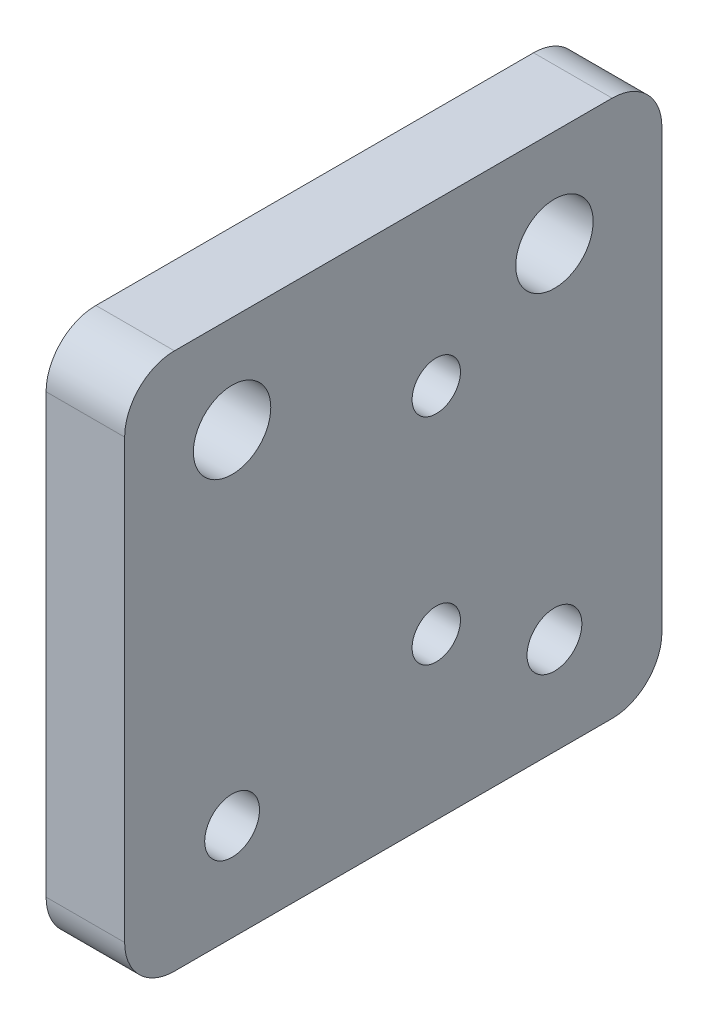
from build123d import *

# Parameters (mm, degrees)
SKETCH2_W            = 50
SKETCH2_H            = 50
BOSS_EXTRUDE1_DEPTH  = 7.31
SKETCH6_R            = 3.6
SKETCH6_R_2          = 2.55
CUT_EXTRUDE2_DEPTH   = 8.31
SKETCH7_R            = 5.05
SKETCH7_R_2          = 6
CUT_EXTRUDE3_DEPTH   = 2
M4_CLEARANCE_HOLE1_D = 4.5
FILLET1_R            = 4.635


with BuildPart() as part:
    # Sketch2 → Boss-Extrude1 (new body)
    with BuildSketch(Plane(origin=(0, 0, 0), x_dir=(0, 0, -1), z_dir=(1, 0, 0))):
        Rectangle(SKETCH2_W, SKETCH2_H)
    extrude(amount=BOSS_EXTRUDE1_DEPTH)

    # Sketch6 → Cut-Extrude2 (cut, through all)
    with BuildSketch(Plane(origin=(0, 0, 0), x_dir=(0, 0, -1), z_dir=(1, 0, 0))):
        with Locations((-15, 15.95)):
            Circle(SKETCH6_R)
        with Locations((15, 15.95)):
            Circle(SKETCH6_R)
        with Locations((-15, -15.95)):
            Circle(SKETCH6_R_2)
        with Locations((15, -15.95)):
            Circle(SKETCH6_R_2)
    extrude(amount=CUT_EXTRUDE2_DEPTH, mode=Mode.SUBTRACT)

    # Sketch7 → Cut-Extrude3 (cut)
    with BuildSketch(Plane.ZY):
        with Locations((-15, -15.95)):
            Circle(SKETCH7_R)
        with Locations((15, -15.95)):
            Circle(SKETCH7_R)
        with Locations((-15, 15.95)):
            Circle(SKETCH7_R_2)
        with Locations((15, 15.95)):
            Circle(SKETCH7_R_2)
    extrude(amount=-CUT_EXTRUDE3_DEPTH, mode=Mode.SUBTRACT)

    # M4 Clearance Hole1 (through all)
    with Locations(Plane(origin=(7.31, 0, 0), x_dir=(0, 0, -1), z_dir=(1, 0, 0))):
        with Locations((4, -10), (4, 10)):
            Hole(M4_CLEARANCE_HOLE1_D / 2)

    # Fillet1
    fillet1_edges = [part.edges().sort_by_distance(p)[0] for p in [
        (3.655, -25, -25),
        (3.655, -25, 25),
        (3.655, 25, 25),
        (3.655, 25, -25),
    ]]
    fillet(fillet1_edges, radius=FILLET1_R)


solid = part.part
